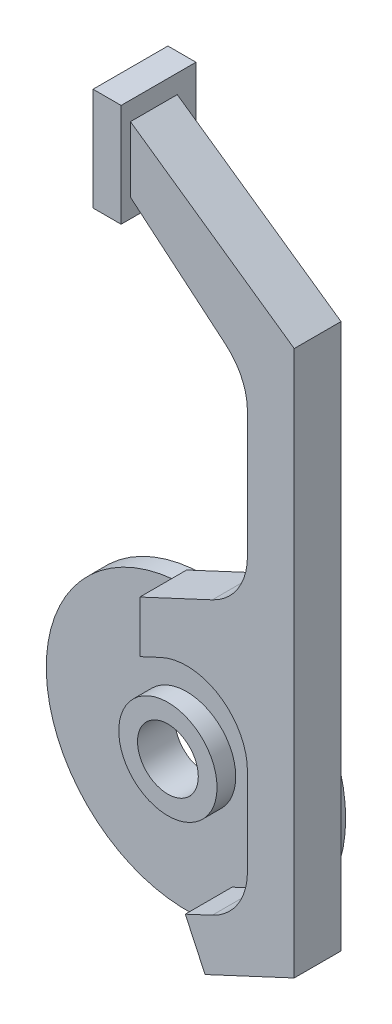
from build123d import *

# Parameters (mm, degrees)
SKETCH1_R               = 30
BOSS_EXTRUDE1_DEPTH     = 4
BOSS_EXTRUDE2_DEPTH     = 10
SKETCH3_W               = 22
SKETCH3_H               = 16
BOSS_EXTRUDE3_DEPTH     = 6
SKETCH5_R               = 10.5
BOSS_EXTRUDE4_DEPTH     = 4
SKETCH7_R               = 6.5
CUT_EXTRUDE3_DEPTH      = 9
CUT_EXTRUDE3_DEPTH_BACK = 9


with BuildPart() as part:
    # Sketch1 → Boss-Extrude1 (new body)
    with BuildSketch(Plane(origin=(0, 0, 0), x_dir=(0, 1, 0), z_dir=(0, 0, 1))):
        Circle(SKETCH1_R)
    extrude(amount=BOSS_EXTRUDE1_DEPTH)

    # Sketch2 → Boss-Extrude2 (add)
    with BuildSketch(Plane.XY.offset(4)):
        with BuildLine():
            Line((9.72022002, -20.845079102), (13.946402637, -29.908156972))
            Line((13.946402637, -29.908156972), (33, -21.023318607))
            Line((33, -21.023318607), (33, 95.492736163))
            Line((33, 95.492736163), (-2, 120))
            Line((-2, 120), (-2, 106))
            Line((-2, 106), (18.356238926, 88.919087425))
            ThreePointArc((18.356238926, 88.919087425), (21.782001231, 84.454547067), (23, 78.960509665))
            Line((23, 78.960509665), (23, 52.006989528))
            ThreePointArc((23, 52.006989528), (20.964088796, 45.02209462), (15.494037403, 40.224988297))
            Line((15.494037403, 40.224988297), (0, 33))
            Line((0, 33), (0, 21.96622081))
            Line((0, 21.96622081), (4.505962597, 24.067385677))
            ThreePointArc((4.505962597, 24.067385677), (16.984894909, 23.249473241), (23, 12.285384445))
            Line((23, 12.285384445), (23, -6.370702608))
            ThreePointArc((23, -6.370702608), (20.964088796, -13.355597517), (15.494037403, -18.15270384))
            Line((15.494037403, -18.15270384), (9.72022002, -20.845079102))
        make_face()
    extrude(amount=BOSS_EXTRUDE2_DEPTH)

    # Sketch3 → Boss-Extrude3 (add)
    with BuildSketch(Plane(origin=(-2, 0, 0), x_dir=(0, -1, 0), z_dir=(-1, 0, 0))):
        with Locations((-113, 8)):
            Rectangle(SKETCH3_W, SKETCH3_H)
    extrude(amount=BOSS_EXTRUDE3_DEPTH)

    # Sketch5 → Boss-Extrude4 (add)
    with BuildSketch(Plane.XY.offset(4)):
        Circle(SKETCH5_R)
    extrude(amount=BOSS_EXTRUDE4_DEPTH)

    # Sketch7 → Cut-Extrude3 (cut, two sides)
    with BuildSketch(Plane.XY.offset(8)) as cut_extrude3_sk:
        Circle(SKETCH7_R)
    extrude(amount=CUT_EXTRUDE3_DEPTH, mode=Mode.SUBTRACT)
    extrude(cut_extrude3_sk.sketch, amount=-CUT_EXTRUDE3_DEPTH_BACK, mode=Mode.SUBTRACT)


solid = part.part
